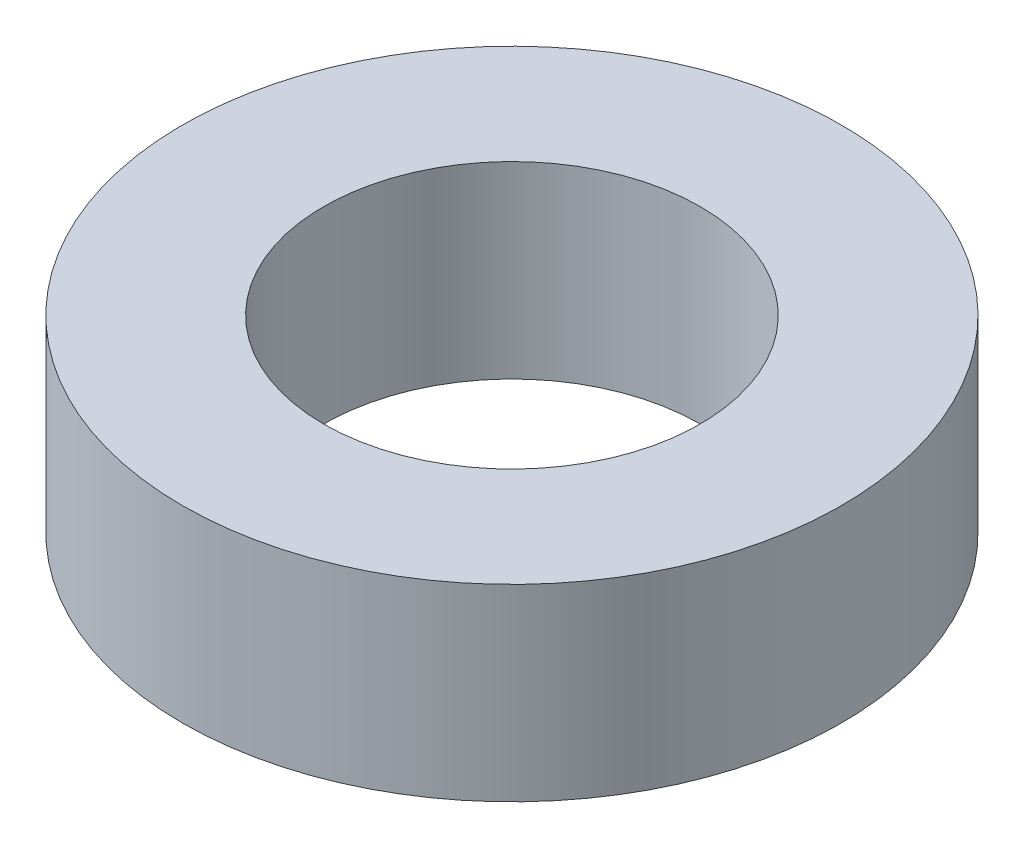
from build123d import *

# Parameters (mm, degrees)
SKETCH1_R           = 7
SKETCH1_R_2         = 4
BOSS_EXTRUDE1_DEPTH = 4


with BuildPart() as part:
    # Sketch1 → Boss-Extrude1 (new body)
    with BuildSketch(Plane(origin=(0, 0, 0), x_dir=(1, 0, 0), z_dir=(0, 1, 0))):
        Circle(SKETCH1_R)
        Circle(SKETCH1_R_2, mode=Mode.SUBTRACT)
    extrude(amount=BOSS_EXTRUDE1_DEPTH)


solid = part.part
